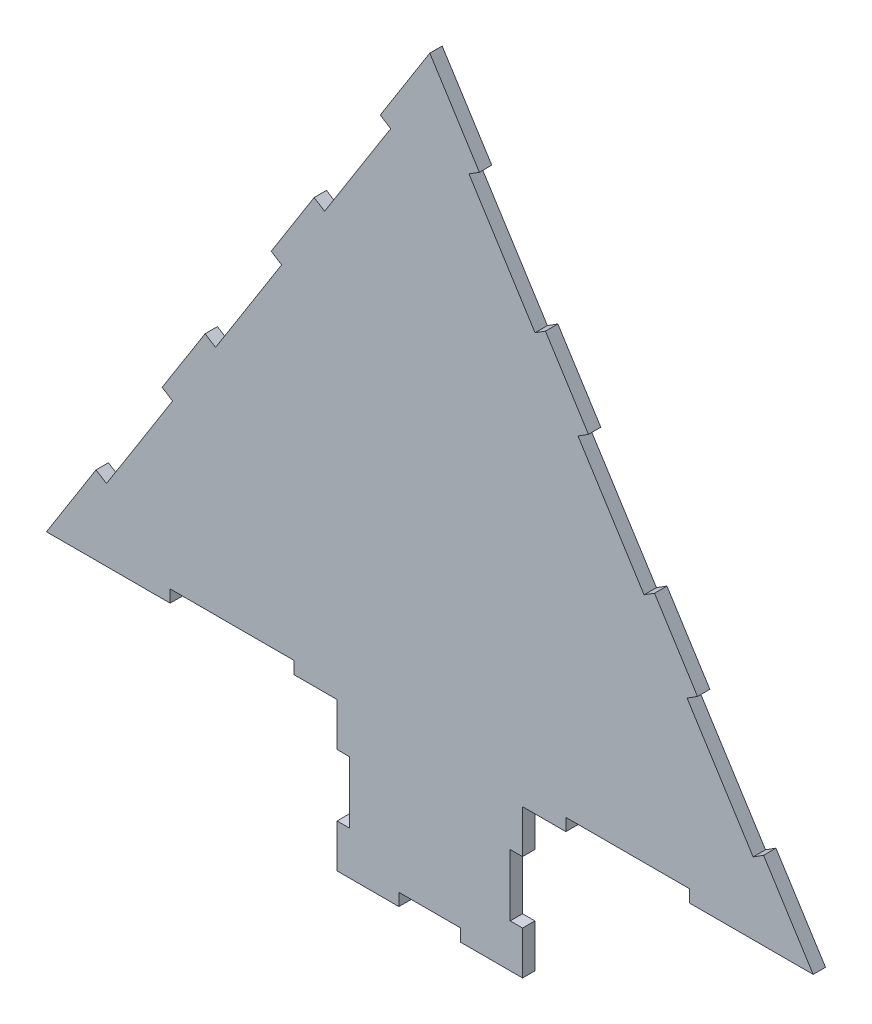
from build123d import *

# Parameters (mm, degrees)
BOSS_EXTRU_1_DEPTH      = 10
ESQUISSE2_W             = 100
ESQUISSE2_H             = 10
ESQUISSE2_W_2           = 10
ESQUISSE2_H_2           = 50
ESQUISSE2_W_3           = 50
ENL_V_MAT_EXTRU_1_DEPTH = 10


with BuildPart() as part:
    # Esquisse1 → Boss.-Extru.1 (new body)
    with BuildSketch(Plane.XY):
        Polygon((-310, 0), (0, 490.204039151), (310, 0), (75, 0), (75, -120), (-75, -120), (-75, 0), align=None)
    extrude(amount=BOSS_EXTRU_1_DEPTH)

    # Esquisse2 → Enlèv. mat.-Extru.1 (cut)
    with BuildSketch(Plane.XY.offset(10)):
        Polygon((-269.913793103, 63.388453338), (-261.461999325, 58.043625752), (-208.013723463, 142.561563537), (-216.465517241, 147.906391123), align=None)
        Polygon((-181.724137931, 202.843050683), (-173.272344153, 197.498223097), (-119.82406829, 282.016160882), (-128.275862069, 287.360988468), align=None)
        Polygon((-93.534482759, 342.297648028), (-85.08268898, 336.952820442), (-31.634413118, 421.470758226), (-40.086206897, 426.815585813), align=None)
        Polygon((208.013723463, 142.561563537), (216.465517241, 147.906391123), (269.913793103, 63.388453338), (261.461999325, 58.043625752), align=None)
        Polygon((31.634413118, 421.470758226), (40.086206897, 426.815585813), (93.534482759, 342.297648028), (85.08268898, 336.952820442), align=None)
        Polygon((119.82406829, 282.016160882), (128.275862069, 287.360988468), (181.724137931, 202.843050683), (173.272344153, 197.498223097), align=None)
        with Locations((-160, 5)):
            Rectangle(ESQUISSE2_W, ESQUISSE2_H)
        with Locations((160, 5)):
            Rectangle(ESQUISSE2_W, ESQUISSE2_H)
        with Locations((-70, -60)):
            Rectangle(ESQUISSE2_W_2, ESQUISSE2_H_2)
        with Locations((70, -60)):
            Rectangle(ESQUISSE2_W_2, ESQUISSE2_H_2)
        with Locations((0, -115)):
            Rectangle(ESQUISSE2_W_3, ESQUISSE2_H)
    extrude(amount=-ENL_V_MAT_EXTRU_1_DEPTH, mode=Mode.SUBTRACT)


solid = part.part
